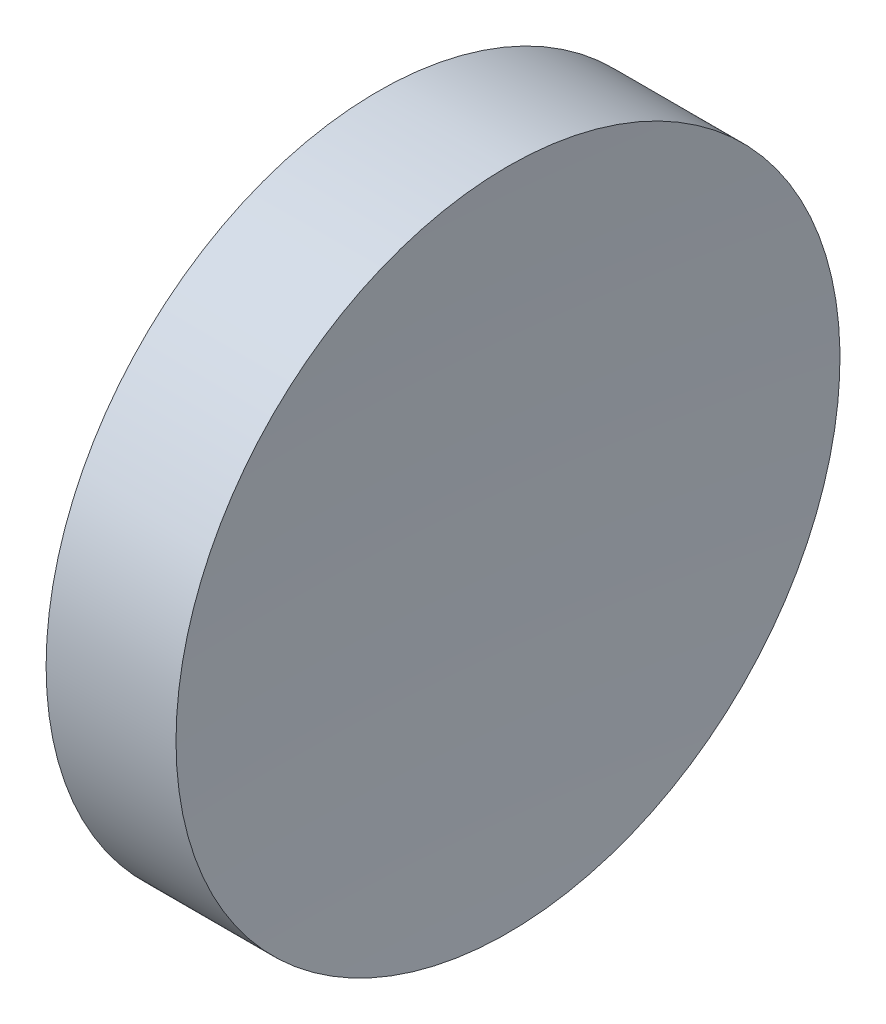
from build123d import *


with BuildPart() as part:
    # 草图1 → 旋转1 (revolve)
    with BuildSketch(Plane.XY):
        with BuildLine():
            Line((230.18531107, 138.756042247), (230.18531107, 163.756042247))
            Line((230.18531107, 163.756042247), (239.9673255, 163.756042247))
            ThreePointArc((239.9673255, 163.756042247), (239.380862476, 151.262156217), (239.185311067, 138.756042247))
            Line((239.185311067, 138.756042247), (230.18531107, 138.756042247))
        make_face()
    revolve(axis=Axis((217.970286004, 138.756042247, 0), (1, 0, 0)))


solid = part.part
